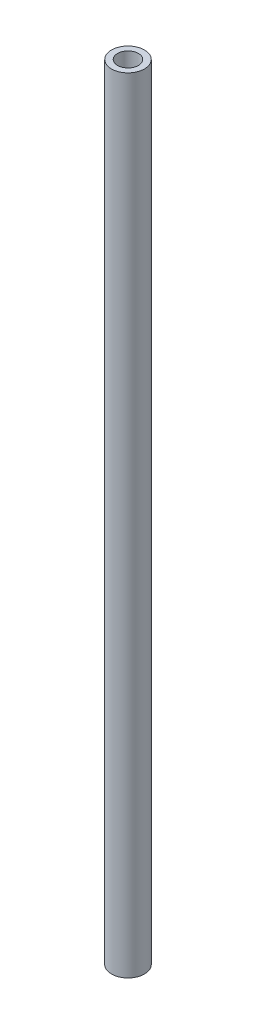
from build123d import *

# Parameters (mm, degrees)
SKETCH_1_R      = 3.15
SKETCH_1_R_2    = 2
EXTRUDE_1_DEPTH = 150


with BuildPart() as part:
    # 草图1 → 凸台-拉伸1 (new body)
    with BuildSketch(Plane(origin=(0, 0, 0), x_dir=(1, 0, 0), z_dir=(0, 1, 0))):
        Circle(SKETCH_1_R)
        Circle(SKETCH_1_R_2, mode=Mode.SUBTRACT)
    extrude(amount=EXTRUDE_1_DEPTH)


solid = part.part
